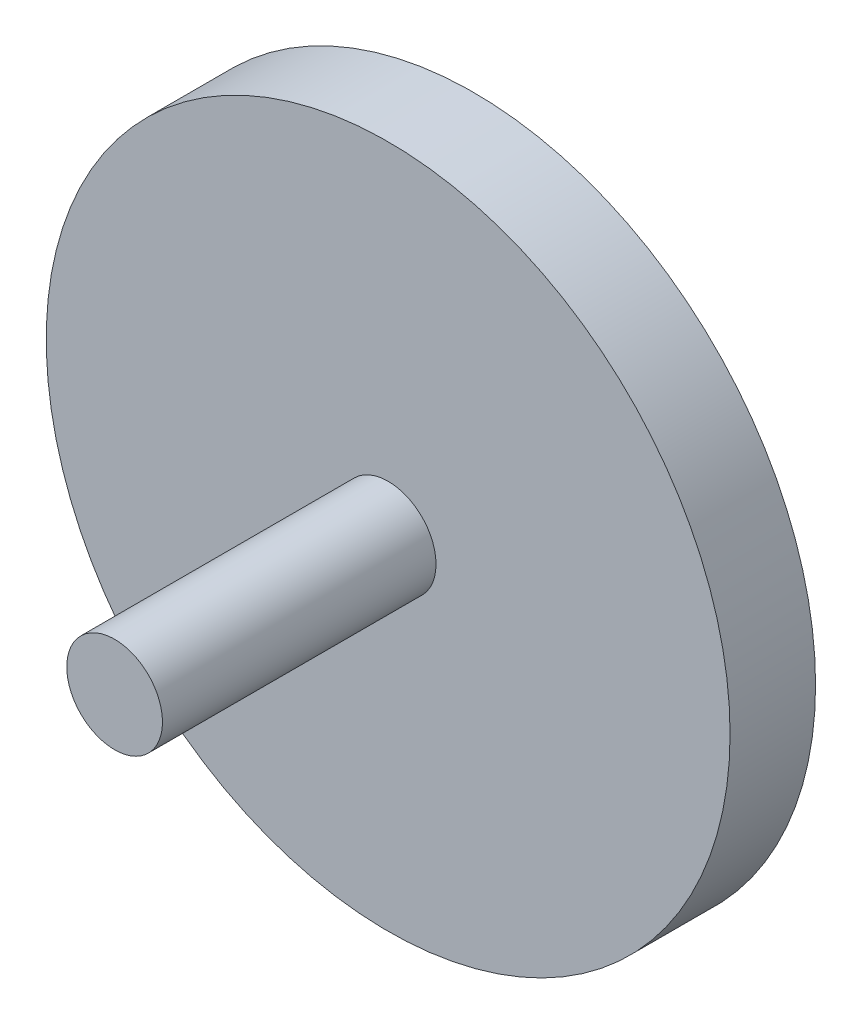
from build123d import *

# Parameters (mm, degrees)
SKETCH1_R           = 100
BOSS_EXTRUDE1_DEPTH = 25
SKETCH2_R           = 14
BOSS_EXTRUDE2_DEPTH = 80
SKETCH3_R           = 10
CUT_EXTRUDE1_DEPTH  = 4


with BuildPart() as part:
    # Sketch1 → Boss-Extrude1 (new body)
    with BuildSketch(Plane.XY):
        Circle(SKETCH1_R)
    extrude(amount=BOSS_EXTRUDE1_DEPTH)

    # Sketch2 → Boss-Extrude2 (add)
    with BuildSketch(Plane.XY.offset(25)):
        Circle(SKETCH2_R)
    extrude(amount=BOSS_EXTRUDE2_DEPTH)

    # Sketch3 → Cut-Extrude1 (cut)
    with BuildSketch(Plane(origin=(0, 0, 0), x_dir=(-1, 0, 0), z_dir=(0, 0, -1))):
        with Locations((0, 50)):
            Circle(SKETCH3_R)
    extrude(amount=-CUT_EXTRUDE1_DEPTH, mode=Mode.SUBTRACT)


solid = part.part
